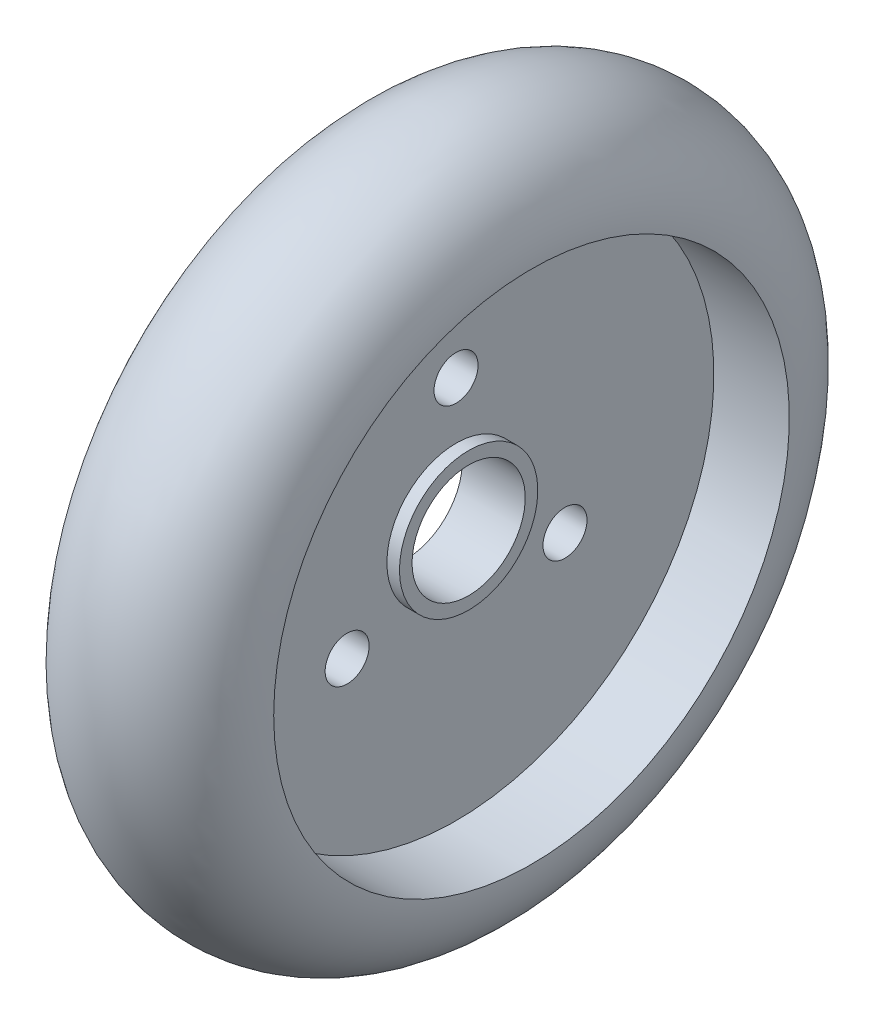
from build123d import *

# Parameters (mm, degrees)
SKETCH_2_R               = 1.75
CUT_EXTRUDE_1_DEPTH      = 8.5
CUT_EXTRUDE_1_DEPTH_BACK = 8.5


with BuildPart() as part:
    # ｽｹｯﾁ1 → 回転1 (revolve)
    with BuildSketch(Plane.XY):
        with BuildLine():
            Line((-2.5, 4.5), (2.5, 4.5))
            Line((2.5, 4.5), (2.5, 5.5))
            Line((2.5, 5.5), (1.5, 5.5))
            Line((1.5, 5.5), (1.5, 20.5))
            Line((1.5, 20.5), (7.5, 20.5))
            ThreePointArc((7.5, 20.5), (0, 28), (-7.5, 20.5))
            Line((-7.5, 20.5), (-1.5, 20.5))
            Line((-1.5, 20.5), (-1.5, 5.5))
            Line((-1.5, 5.5), (-2.5, 5.5))
            Line((-2.5, 5.5), (-2.5, 4.5))
        make_face()
    revolve(axis=Axis((0, 0, 0), (1, 0, 0)))

    # ｽｹｯﾁ2 → ｶｯﾄ - 押し出し1 (cut, two sides)
    with BuildSketch(Plane(origin=(0, 0, 0), x_dir=(0, 0, -1), z_dir=(1, 0, 0))) as cut_extrude_1_sk:
        with Locations((0, 10)):
            Circle(SKETCH_2_R)
        with Locations((8.660254038, -5)):
            Circle(SKETCH_2_R)
        with Locations((-8.660254038, -5)):
            Circle(SKETCH_2_R)
    extrude(amount=CUT_EXTRUDE_1_DEPTH, mode=Mode.SUBTRACT)
    extrude(cut_extrude_1_sk.sketch, amount=-CUT_EXTRUDE_1_DEPTH_BACK, mode=Mode.SUBTRACT)


solid = part.part
